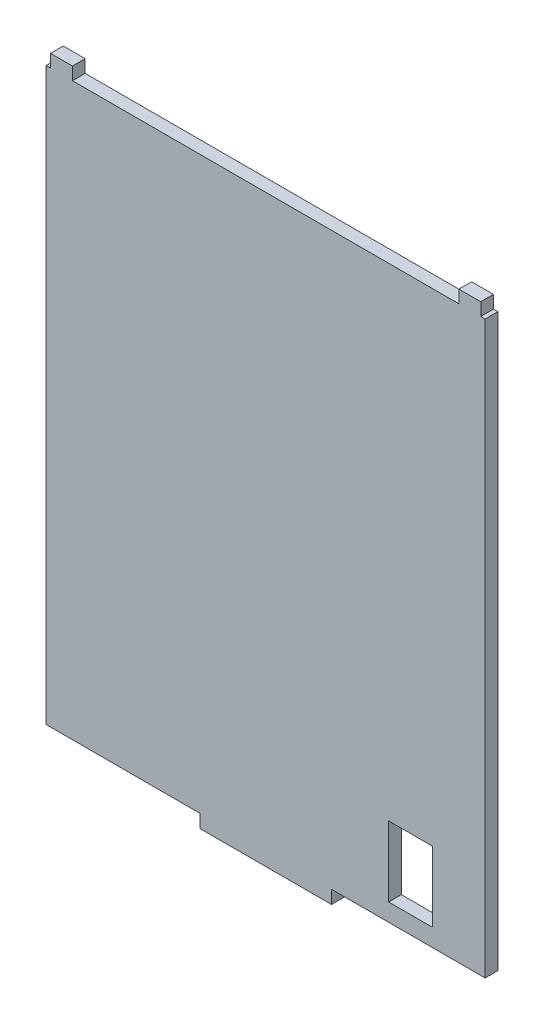
from build123d import *

# Parameters (mm, degrees)
EXTRUDE_1_DEPTH = 2.9


with BuildPart() as part:
    # 草图1 → 凸台-拉伸1 (new body)
    with BuildSketch(Plane.XY):
        Polygon((65, -3), (65, 0), (100, 0), (100, 130), (99, 130), (99, 132.9), (95, 132.9), (94, 132.9), (94, 130), (6, 130), (6, 132.9), (5, 132.9), (1, 132.9), (1, 130), (0, 130), (0, 0), (35, 0), (35, -3), (50, -3), align=None)
        Polygon((83, 4), (78, 4), (78, 20), (83, 20), (88, 20), (88, 4), align=None, mode=Mode.SUBTRACT)
    extrude(amount=EXTRUDE_1_DEPTH)


solid = part.part
